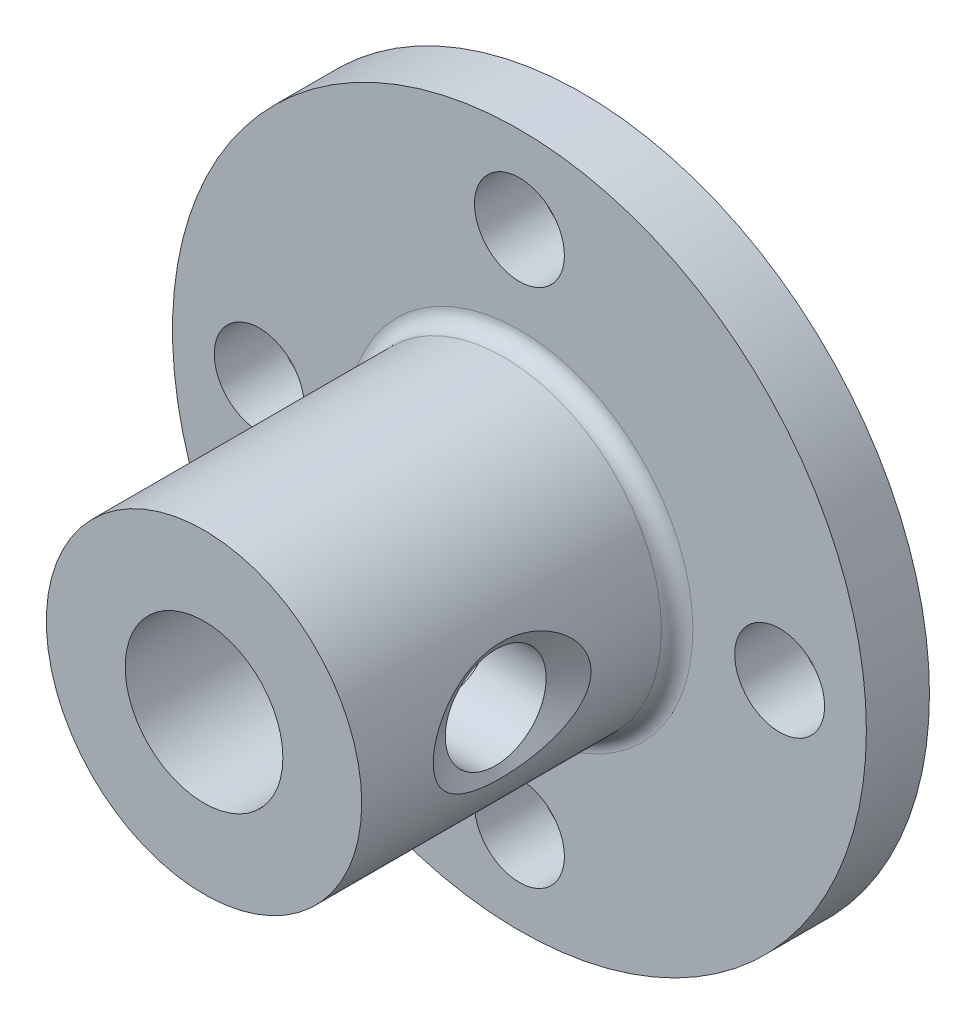
from build123d import *

# Parameters (mm, degrees)
SKETCH1_R                                       = 5
SKETCH1_R_2                                     = 2.5
BOSS_EXTRUDE2_DEPTH                             = 12
SKETCH3_R                                       = 11
SKETCH3_R_2                                     = 5
BOSS_EXTRUDE3_DEPTH                             = 2
FILLET1_R                                       = 0.5
CUT_EXTRUDE1_DEPTH                              = 2
CIRPATTERN1_COUNT                               = 4
CSK_FOR_M3_FLAT_HEAD_MACHINE_SCREW2_D           = 3.2
CSK_FOR_M3_FLAT_HEAD_MACHINE_SCREW2_CSINK_D     = 5
CSK_FOR_M3_FLAT_HEAD_MACHINE_SCREW2_CSINK_ANGLE = 120


with BuildPart() as part:
    # Sketch1 → Boss-Extrude2 (new body)
    with BuildSketch(Plane.XY):
        Circle(SKETCH1_R)
        Circle(SKETCH1_R_2, mode=Mode.SUBTRACT)
    extrude(amount=BOSS_EXTRUDE2_DEPTH)

    # Sketch3 → Boss-Extrude3 (add)
    with BuildSketch(Plane.XY):
        Circle(SKETCH3_R)
        Circle(SKETCH3_R_2, mode=Mode.SUBTRACT)
    extrude(amount=BOSS_EXTRUDE3_DEPTH)

    # Fillet1
    fillet1_edges = [part.edges().sort_by_distance(p)[0] for p in [
        (-5, 0, 2),
    ]]
    fillet(fillet1_edges, radius=FILLET1_R)

    # Sketch5 → Cut-Extrude1 (cut)
    with BuildSketch(Plane.XY.offset(2)):
        with BuildLine():
            ThreePointArc((-1.419675746, 8.126931818), (-0.963133646, 7.199762608), (0, 6.825))
            Line((0, 6.825), (0, 8.25))
            ThreePointArc((0, 8.25), (-0.7125, 8.219175369), (-1.419675746, 8.126931818))
        make_face()
        with BuildLine():
            Line((0, 8.25), (0, 6.825))
            ThreePointArc((0, 6.825), (0.963133646, 7.199762608), (1.419675746, 8.126931818))
            ThreePointArc((1.419675746, 8.126931818), (0.7125, 8.219175369), (0, 8.25))
        make_face()
        with BuildLine():
            ThreePointArc((-1.419675746, 8.126931818), (-0.7125, 8.219175369), (0, 8.25))
            Line((0, 8.25), (0, 9.675))
            ThreePointArc((0, 9.675), (-1.050237392, 9.213133646), (-1.419675746, 8.126931818))
        make_face()
        with BuildLine():
            Line((0, 9.675), (0, 8.25))
            ThreePointArc((0, 8.25), (0.7125, 8.219175369), (1.419675746, 8.126931818))
            ThreePointArc((1.419675746, 8.126931818), (1.423668314, 8.188408351), (1.425, 8.25))
            ThreePointArc((1.425, 8.25), (1.007627163, 9.257627163), (0, 9.675))
        make_face()
    cut_extrude1 = extrude(amount=-CUT_EXTRUDE1_DEPTH, mode=Mode.SUBTRACT)

    # CirPattern1: Cut-Extrude1 ×4 about axis
    cirpattern1_axis = Axis((0, 0, 0), (0, 0, 1))
    for i in range(1, CIRPATTERN1_COUNT):
        add(cut_extrude1.rotate(cirpattern1_axis, i * 360 / CIRPATTERN1_COUNT), mode=Mode.SUBTRACT)

    # CSK for M3 Flat Head Machine Screw2 (through all)
    with Locations(Plane(origin=(4.999975674, -0.015596745, 7.232142879), x_dir=(0.003119349, 0.999995135, 0), z_dir=(0.999995135, -0.003119349, 0))):
        with Locations((0, 0)):
            CounterSinkHole(CSK_FOR_M3_FLAT_HEAD_MACHINE_SCREW2_D / 2, CSK_FOR_M3_FLAT_HEAD_MACHINE_SCREW2_CSINK_D / 2, counter_sink_angle=CSK_FOR_M3_FLAT_HEAD_MACHINE_SCREW2_CSINK_ANGLE)


solid = part.part
